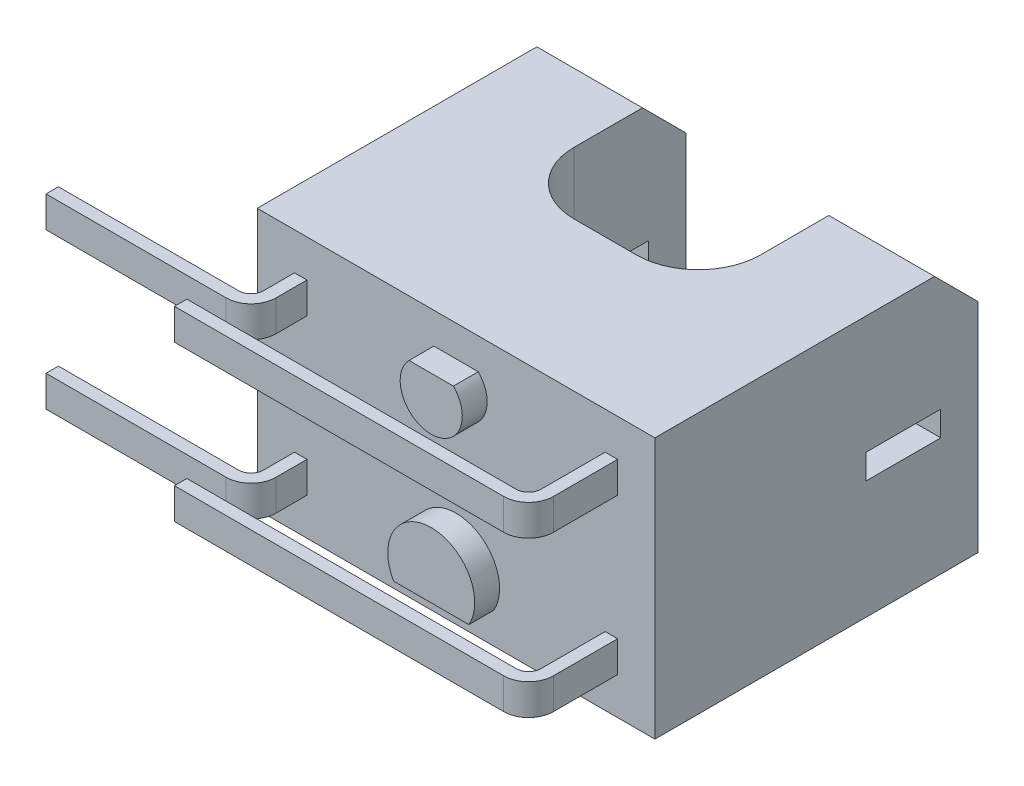
from build123d import *

# Parameters (mm, degrees)
EXTRUDE_1_DEPTH     = 4.2
CHAMFER_1_SIZE      = 0.7
SKETCH_2_W          = 1.2
SKETCH_2_H          = 0.4
CUT_EXTRUDE_1_DEPTH = 7.4
SKETCH_3_W          = 0.2
SKETCH_3_H          = 0.5
EXTRUDE_2_DEPTH     = 0.4
SKETCH_4_W          = 0.2
SKETCH_4_H          = 0.5
SKETCH_5_W          = 0.2
SKETCH_5_H          = 0.5


with BuildPart() as part:
    # Эскиз1 → Бобышка-Вытянуть1 (new body)
    with BuildSketch(Plane(origin=(0, 0, 0), x_dir=(1, 0, 0), z_dir=(0, 1, 0))):
        with BuildLine():
            Line((-3.2, 0), (-3.2, 5.2))
            Line((-3.2, 5.2), (-1.5, 5.2))
            Line((-1.5, 5.2), (-1.5, 3.4))
            ThreePointArc((-1.5, 3.4), (-1.207106781, 2.692893219), (-0.5, 2.4))
            Line((-0.5, 2.4), (0.5, 2.4))
            ThreePointArc((0.5, 2.4), (1.207106781, 2.692893219), (1.5, 3.4))
            Line((1.5, 3.4), (1.5, 5.2))
            Line((1.5, 5.2), (3.2, 5.2))
            Line((3.2, 5.2), (3.2, 0))
            Line((3.2, 0), (-3.2, 0))
        make_face()
    extrude(amount=EXTRUDE_1_DEPTH)

    # Фаска1
    chamfer_1_edges = [part.edges().sort_by_distance(p)[0] for p in [
        (2.35, 4.2, -5.2),
        (-2.35, 4.2, -5.2),
    ]]
    chamfer(chamfer_1_edges, length=CHAMFER_1_SIZE)

    # Эскиз2 → Вырез-Вытянуть1 (cut, through all)
    with BuildSketch(Plane.ZY.offset(3.2)):
        with Locations((-4, 2.1)):
            Rectangle(SKETCH_2_W, SKETCH_2_H)
    extrude(amount=-CUT_EXTRUDE_1_DEPTH, mode=Mode.SUBTRACT)

    # Эскиз3 → Бобышка-Вытянуть2 (add)
    with BuildSketch(Plane.XY):
        with BuildLine():
            Line((-0.357071421, 3.7), (0.357071421, 3.7))
            ThreePointArc((0.357071421, 3.7), (0, 2.85), (-0.357071421, 3.7))
        make_face()
        with BuildLine():
            Line((-0.606217783, 0.5), (0.606217783, 0.5))
            ThreePointArc((0.606217783, 0.5), (0, 1.55), (-0.606217783, 0.5))
        make_face()
        with Locations((-2.5, 3.35)):
            Rectangle(SKETCH_3_W, SKETCH_3_H)
        with Locations((2.5, 3.35)):
            Rectangle(SKETCH_3_W, SKETCH_3_H)
        with Locations((2.5, 0.85)):
            Rectangle(SKETCH_3_W, SKETCH_3_H)
        with Locations((-2.5, 0.85)):
            Rectangle(SKETCH_3_W, SKETCH_3_H)
    extrude(amount=EXTRUDE_2_DEPTH)

    # По траектории1: sweep along a curve in space
    with BuildLine() as sweep_1_path:
        Line((2.4, 3.1, 0.4), (2.4, 3.1, 1.033279954))
        ThreePointArc((2.2, 3.1, 1.233279954), (2.341421356, 3.1, 1.17470131), (2.4, 3.1, 1.033279954))
        Line((2.2, 3.1, 1.233279954), (-3.1, 3.1, 1.233279954))
    # Эскиз4 → По траектории1 (sweep)
    with BuildSketch(Plane.XY.offset(0.4)):
        with Locations((2.5, 3.35)):
            Rectangle(SKETCH_4_W, SKETCH_4_H)
        with Locations((2.5, 0.85)):
            Rectangle(SKETCH_4_W, SKETCH_4_H)
    sweep(path=sweep_1_path.line)

    # По траектории2: sweep along a curve in space
    with BuildLine() as sweep_2_path:
        Line((-2.6, 0.6, 0.4), (-2.6, 0.6, 0.5))
        ThreePointArc((-2.8, 0.6, 0.7), (-2.658578644, 0.6, 0.641421356), (-2.6, 0.6, 0.5))
        Line((-2.8, 0.6, 0.7), (-5.7, 0.6, 0.7))
    # Эскиз5 → По траектории2 (sweep)
    with BuildSketch(Plane.XY.offset(0.4)):
        with Locations((-2.5, 3.35)):
            Rectangle(SKETCH_5_W, SKETCH_5_H)
        with Locations((-2.5, 0.85)):
            Rectangle(SKETCH_5_W, SKETCH_5_H)
    sweep(path=sweep_2_path.line)


solid = part.part
